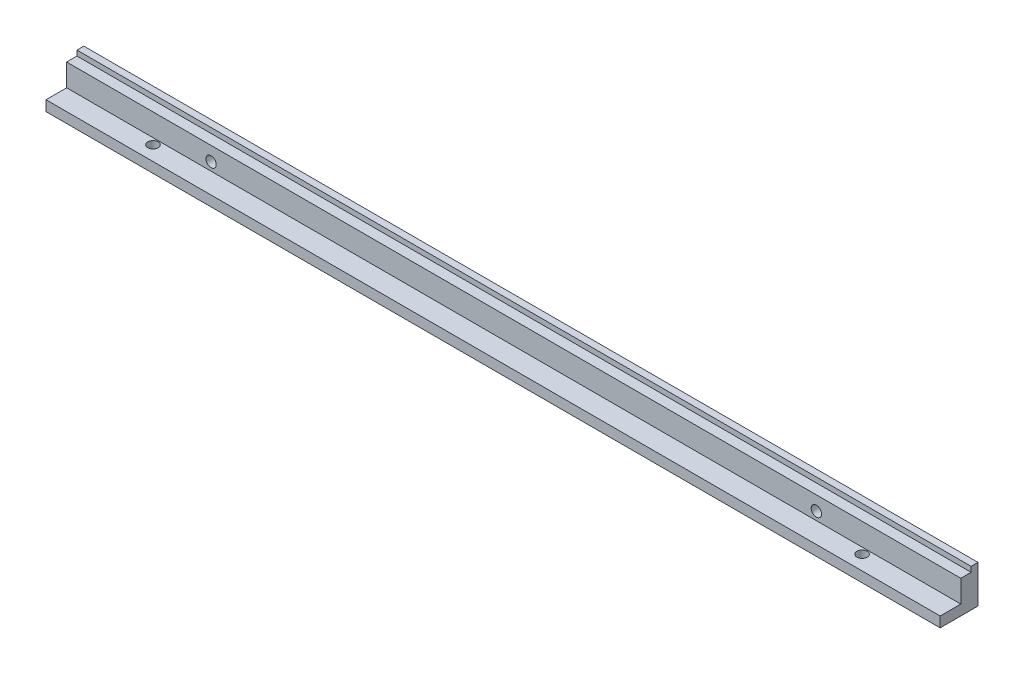
from build123d import *

# Parameters (mm, degrees)
EXTRUDE_1_DEPTH     = 260
SKETCH_4_R          = 1.5
CUT_EXTRUDE_3_DEPTH = 6
SKETCH_5_R          = 1.5
CUT_EXTRUDE_4_DEPTH = 4


with BuildPart() as part:
    # Эскиз1 → Бобышка-Вытянуть1 (new body)
    with BuildSketch(Plane(origin=(0, 0, 0), x_dir=(0, 0, -1), z_dir=(1, 0, 0))):
        Polygon((0, 0), (-11, 0), (-11, 3), (-5, 3), (-5, 9.5), (-2, 9.5), (-2, 11), (0, 11), align=None)
    extrude(amount=EXTRUDE_1_DEPTH)

    # Эскиз4 → Вырез-Вытянуть3 (cut, through all)
    with BuildSketch(Plane.XY.offset(5)):
        with Locations((42, 5.4)):
            Circle(SKETCH_4_R)
        with Locations((218, 5.4)):
            Circle(SKETCH_4_R)
    extrude(amount=-CUT_EXTRUDE_3_DEPTH, mode=Mode.SUBTRACT)

    # Эскиз5 → Вырез-Вытянуть4 (cut, through all)
    with BuildSketch(Plane(origin=(0, 3, 0), x_dir=(1, 0, 0), z_dir=(0, 1, 0))):
        with Locations((26.91, -6.8)):
            Circle(SKETCH_5_R)
        with Locations((233.09, -6.8)):
            Circle(SKETCH_5_R)
    extrude(amount=-CUT_EXTRUDE_4_DEPTH, mode=Mode.SUBTRACT)


solid = part.part
